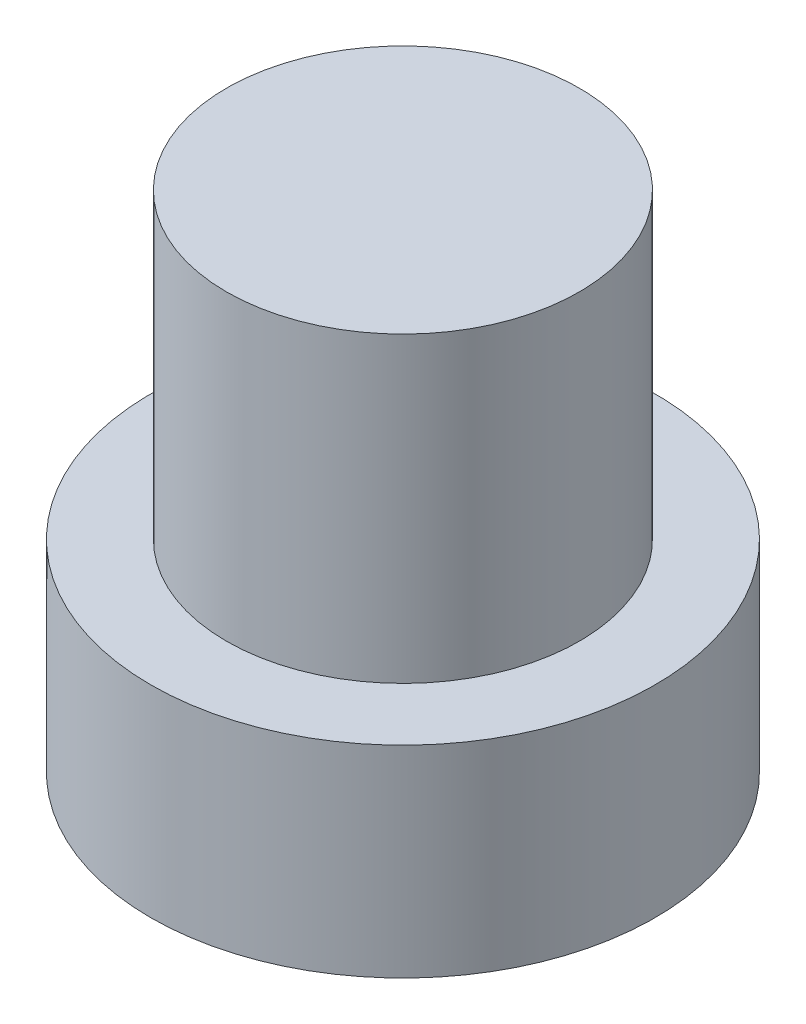
from build123d import *

# Parameters (mm, degrees)
SKETCH1_R           = 5
BOSS_EXTRUDE1_DEPTH = 4
SKETCH2_R           = 3.5
BOSS_EXTRUDE2_DEPTH = 6


with BuildPart() as part:
    # Sketch1 → Boss-Extrude1 (new body)
    with BuildSketch(Plane(origin=(0, 0, 0), x_dir=(1, 0, 0), z_dir=(0, 1, 0))):
        Circle(SKETCH1_R)
    extrude(amount=BOSS_EXTRUDE1_DEPTH)

    # Sketch2 → Boss-Extrude2 (add)
    with BuildSketch(Plane(origin=(0, 4, 0), x_dir=(1, 0, 0), z_dir=(0, 1, 0))):
        Circle(SKETCH2_R)
    extrude(amount=BOSS_EXTRUDE2_DEPTH)


solid = part.part
